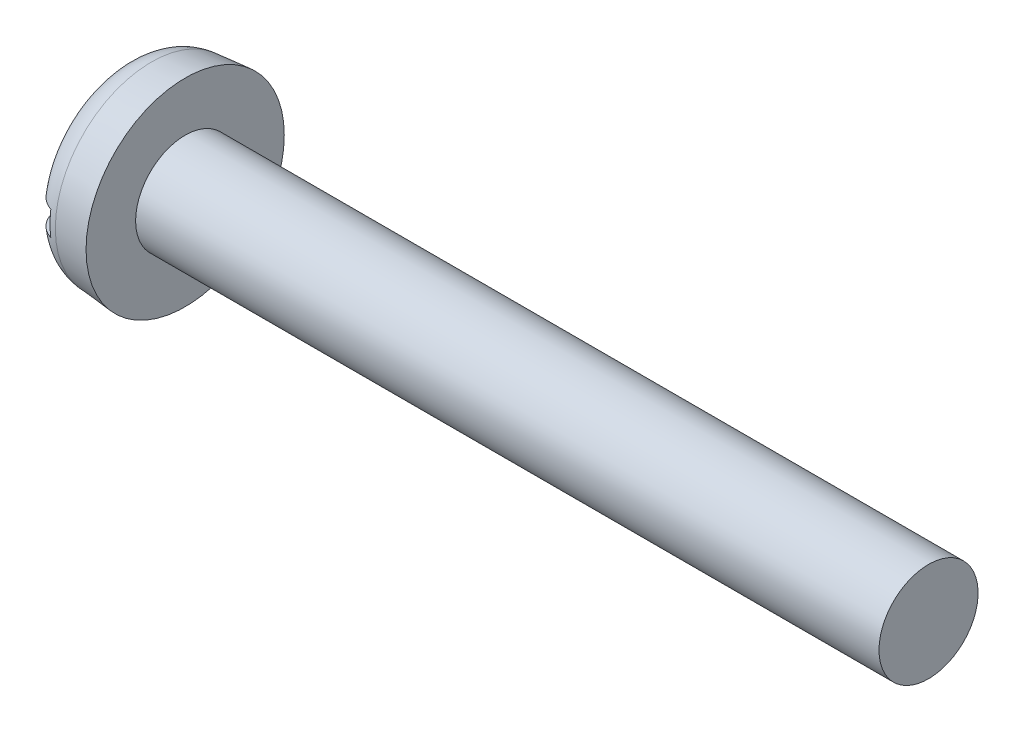
from build123d import *

# Parameters (mm, degrees)
FILLET2_R  = 0.5
SKETCH2_W  = 3.2
SKETCH2_H  = 0.4
SLOT_DEPTH = 0.35


with BuildPart() as part:
    # BodySke → Base-Revolve (revolve)
    with BuildSketch(Plane.XY):
        Polygon((1, 0.8), (1, 1.6), (0, 1.512511336), (0, 0), (13, 0), (13, 0.8), align=None)
    revolve(axis=Axis((-25.4, 0, 0), (1, 0, 0)))

    # Fillet2
    fillet2_edges = [part.edges().sort_by_distance(p)[0] for p in [
        (0, -1.512511336, 0),
    ]]
    fillet(fillet2_edges, radius=FILLET2_R)

    # Sketch2 → Slot (cut)
    with BuildSketch(Plane(origin=(0, 0, 0), x_dir=(0, 0, -1), z_dir=(1, 0, 0))):
        Rectangle(SKETCH2_W, SKETCH2_H)
    extrude(amount=SLOT_DEPTH, mode=Mode.SUBTRACT)


solid = part.part
